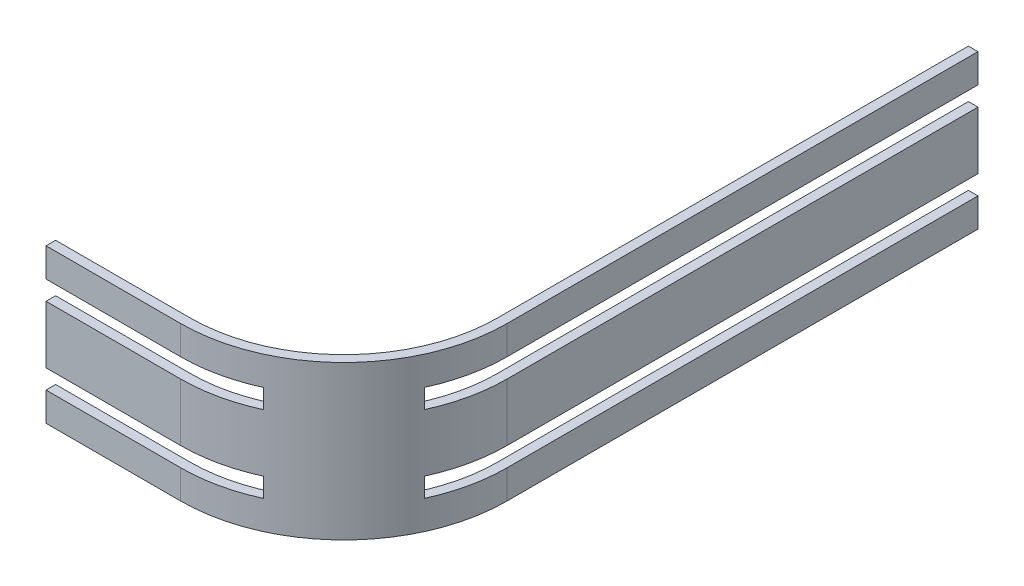
from build123d import *
from build123d.topology import SkipClean

# Parameters (mm, degrees)
EXTRUDE1_DEPTH = 3
EXTRUDE2_DEPTH = 2
EXTRUDE3_DEPTH = 2
EXTRUDE4_DEPTH = 3
EXTRUDE5_DEPTH = 3


with BuildPart() as part:
    # Sketch1 → Extrude1 (new body, symmetric)
    with BuildSketch(Plane(origin=(0, 0, 0), x_dir=(1, 0, 0), z_dir=(0, 1, 0))):
        with BuildLine():
            Line((15, 32.5), (15, -16.5))
            ThreePointArc((15, -16.5), (10.313708499, -27.813708499), (-1, -32.5))
            Line((-1, -32.5), (-15, -32.5))
            Line((-15, -32.5), (-15, -33.5))
            Line((-15, -33.5), (-1, -33.5))
            ThreePointArc((-1, -33.5), (11.02081528, -28.52081528), (16, -16.5))
            Line((16, -16.5), (16, 32.5))
            Line((16, 32.5), (15, 32.5))
        make_face()
    extrude(amount=EXTRUDE1_DEPTH, both=True)

    # Sketch2 → Extrude2 (add)
    with BuildSketch(Plane(origin=(0, 3, 0), x_dir=(1, 0, 0), z_dir=(0, 1, 0))):
        with BuildLine():
            Line((6.075, -30.850762175), (6.075, -31.957825688))
            ThreePointArc((6.075, -31.957825688), (11.02081528, -28.52081528), (14.457825688, -23.575))
            Line((14.457825688, -23.575), (13.350762175, -23.575))
            ThreePointArc((13.350762175, -23.575), (10.313708499, -27.813708499), (6.075, -30.850762175))
        make_face()
    extrude(amount=EXTRUDE2_DEPTH)

    # Sketch3 → Extrude3 (add)
    with BuildSketch(Plane.XZ.offset(3)):
        with BuildLine():
            Line((6.075, 31.957825688), (6.075, 30.850762175))
            ThreePointArc((6.075, 30.850762175), (10.313708499, 27.813708499), (13.350762175, 23.575))
            Line((13.350762175, 23.575), (14.457825688, 23.575))
            ThreePointArc((14.457825688, 23.575), (11.02081528, 28.52081528), (6.075, 31.957825688))
        make_face()
    extrude(amount=EXTRUDE3_DEPTH)

    # Sketch4 → Extrude4 (add)
    with BuildSketch(Plane.XZ.offset(5)):
        with BuildLine():
            Line((16, -32.5), (15, -32.5))
            Line((15, -32.5), (15, 16.5))
            ThreePointArc((15, 16.5), (14.582236598, 20.132341201), (13.350762175, 23.575))
            ThreePointArc((13.350762175, 23.575), (10.313708499, 27.813708499), (6.075, 30.850762175))
            ThreePointArc((6.075, 30.850762175), (2.632341201, 32.082236598), (-1, 32.5))
            Line((-1, 32.5), (-15, 32.5))
            Line((-15, 32.5), (-15, 33.5))
            Line((-15, 33.5), (-1, 33.5))
            ThreePointArc((-1, 33.5), (2.62056372, 33.109982491), (6.075, 31.957825688))
            ThreePointArc((6.075, 31.957825688), (11.02081528, 28.52081528), (14.457825688, 23.575))
            ThreePointArc((14.457825688, 23.575), (15.609982491, 20.12056372), (16, 16.5))
            Line((16, 16.5), (16, -32.5))
        make_face()
    extrude(amount=EXTRUDE4_DEPTH)

    # Sketch5 → Extrude5 (add)
    with SkipClean():  # keep this step's faces unmerged: merging them makes the solid invalid here
        with BuildSketch(Plane(origin=(0, 5, 0), x_dir=(1, 0, 0), z_dir=(0, 1, 0))):
            with BuildLine():
                Line((16, 32.5), (15, 32.5))
                Line((15, 32.5), (15, -16.5))
                ThreePointArc((15, -16.5), (14.582236598, -20.132341201), (13.350762175, -23.575))
                ThreePointArc((13.350762175, -23.575), (10.313708499, -27.813708499), (6.075, -30.850762175))
                ThreePointArc((6.075, -30.850762175), (2.632341201, -32.082236598), (-1, -32.5))
                Line((-1, -32.5), (-15, -32.5))
                Line((-15, -32.5), (-15, -33.5))
                Line((-15, -33.5), (-1, -33.5))
                ThreePointArc((-1, -33.5), (2.62056372, -33.109982491), (6.075, -31.957825688))
                ThreePointArc((6.075, -31.957825688), (11.02081528, -28.52081528), (14.457825688, -23.575))
                ThreePointArc((14.457825688, -23.575), (15.609982491, -20.12056372), (16, -16.5))
                Line((16, -16.5), (16, 32.5))
            make_face()
        extrude(amount=EXTRUDE5_DEPTH)


solid = part.part
